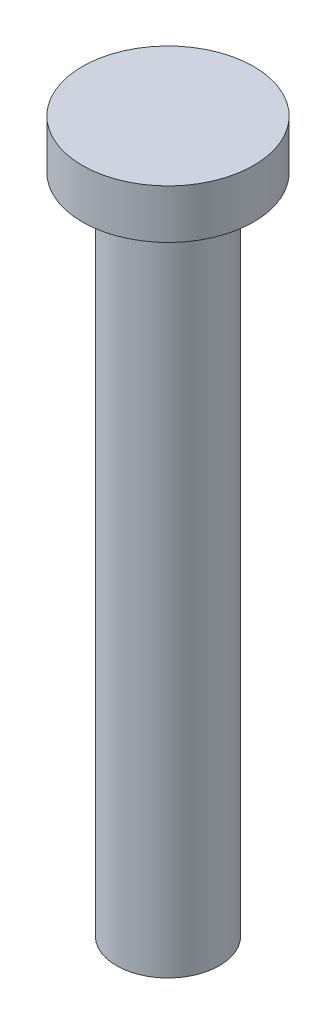
from build123d import *

# Parameters (mm, degrees)
SKETCH1_R           = 2.1
BOSS_EXTRUDE1_DEPTH = 27
SKETCH2_R           = 3.5
BOSS_EXTRUDE3_DEPTH = 2


with BuildPart() as part:
    # Sketch1 → Boss-Extrude1 (new body)
    with BuildSketch(Plane(origin=(0, 0, 0), x_dir=(1, 0, 0), z_dir=(0, 1, 0))):
        Circle(SKETCH1_R)
    extrude(amount=BOSS_EXTRUDE1_DEPTH)

    # Sketch2 → Boss-Extrude3 (add)
    with BuildSketch(Plane(origin=(0, 27, 0), x_dir=(1, 0, 0), z_dir=(0, 1, 0))):
        Circle(SKETCH2_R)
    extrude(amount=BOSS_EXTRUDE3_DEPTH)


solid = part.part
